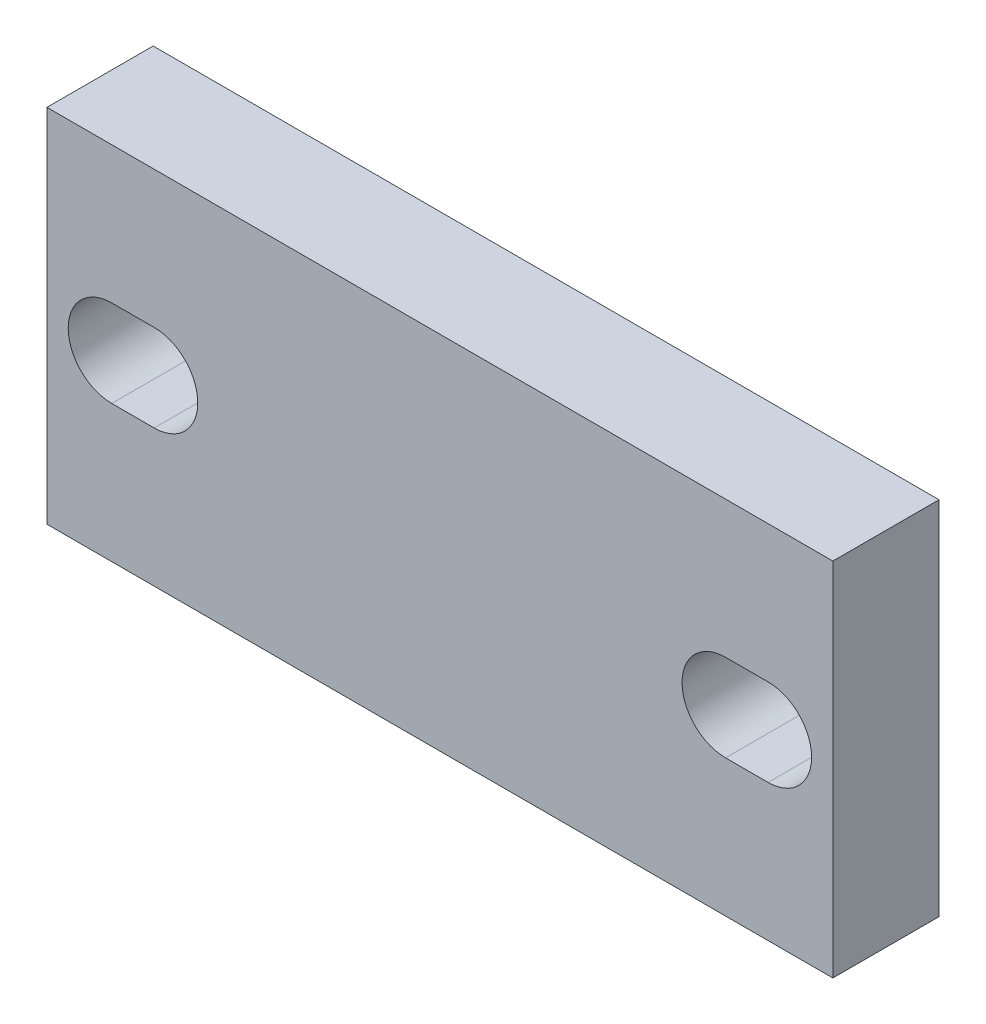
from build123d import *

# Parameters (mm, degrees)
SKETCH1_W           = 37
SKETCH1_H           = 17
BOSS_EXTRUDE1_DEPTH = 5


with BuildPart() as part:
    # Sketch1 → Boss-Extrude1 (new body)
    with BuildSketch(Plane.XY):
        Rectangle(SKETCH1_W, SKETCH1_H)
        with BuildLine():
            Line((-15.45, 2.05), (-13.45, 2.05))
            ThreePointArc((-13.45, 2.05), (-11.4, 0), (-13.45, -2.05))
            Line((-13.45, -2.05), (-15.45, -2.05))
            ThreePointArc((-15.45, -2.05), (-17.5, 0), (-15.45, 2.05))
        make_face(mode=Mode.SUBTRACT)
        with BuildLine():
            Line((15.45, 2.05), (13.45, 2.05))
            ThreePointArc((13.45, 2.05), (11.4, 0), (13.45, -2.05))
            Line((13.45, -2.05), (15.45, -2.05))
            ThreePointArc((15.45, -2.05), (17.5, 0), (15.45, 2.05))
        make_face(mode=Mode.SUBTRACT)
    extrude(amount=BOSS_EXTRUDE1_DEPTH)


solid = part.part
